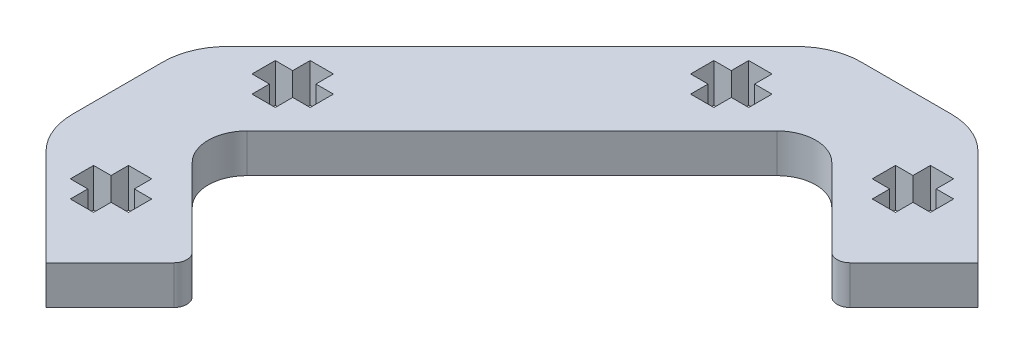
from build123d import *

# Parameters (mm, degrees)
BOSS_EXTRUDE1_DEPTH = 3
CUT_EXTRUDE1_DEPTH  = 4


with BuildPart() as part:
    # Sketch1 → Boss-Extrude1 (new body)
    with BuildSketch(Plane(origin=(0, 0, 0), x_dir=(1, 0, 0), z_dir=(0, 1, 0))):
        with BuildLine():
            Line((-6.037453791, -13.924683413), (-12.047861431, -7.914275773))
            ThreePointArc((-12.047861431, -7.914275773), (-12.926541087, -5.792955429), (-12.047861431, -3.671635086))
            Line((-12.047861431, -3.671635086), (8.458235223, 16.834461569))
            ThreePointArc((8.458235223, 16.834461569), (10.579555567, 17.713141225), (12.700875911, 16.834461569))
            Line((12.700875911, 16.834461569), (18.711283551, 10.824053929))
            ThreePointArc((18.711283551, 10.824053929), (19.418390332, 10.53116071), (20.125497113, 10.824053929))
            Line((20.125497113, 10.824053929), (25.075244581, 15.773801397))
            Line((25.075244581, 15.773801397), (17.606467502, 23.242578477))
            ThreePointArc((17.606467502, 23.242578477), (15.984350757, 24.326442233), (14.070933596, 24.707044571))
            Line((14.070933596, 24.707044571), (7.088177538, 24.707044571))
            ThreePointArc((7.088177538, 24.707044571), (5.174760376, 24.326442233), (3.552643632, 23.242578477))
            Line((3.552643632, 23.242578477), (-18.455978339, 1.233956505))
            ThreePointArc((-18.455978339, 1.233956505), (-19.539842096, -0.388160239), (-19.920444433, -2.301577401))
            Line((-19.920444433, -2.301577401), (-19.920444433, -9.284333458))
            ThreePointArc((-19.920444433, -9.284333458), (-19.539842096, -11.19775062), (-18.455978339, -12.819867364))
            Line((-18.455978339, -12.819867364), (-10.987201259, -20.288644444))
            Line((-10.987201259, -20.288644444), (-6.037453791, -15.338896975))
            ThreePointArc((-6.037453791, -15.338896975), (-5.744560572, -14.631790194), (-6.037453791, -13.924683413))
        make_face()
    extrude(amount=BOSS_EXTRUDE1_DEPTH)

    # Sketch2 → Cut-Extrude1 (cut, through all)
    with BuildSketch(Plane(origin=(0, 3, 0), x_dir=(1, 0, 0), z_dir=(0, 1, 0))):
        Polygon((-15.670444433, 2.136481822), (-15.670444433, 0.336481822), (-14.320444433, 0.336481822), (-14.320444433, -1.013518178), (-12.520444433, -1.013518178), (-12.520444433, 0.336481822), (-11.170444433, 0.336481822), (-11.170444433, 2.136481822), (-12.520444433, 2.136481822), (-12.520444433, 3.486481822), (-14.320444433, 3.486481822), (-14.320444433, 2.136481822), align=None)
        Polygon((-12.520444433, -10.572392681), (-14.320444433, -10.572392681), (-14.320444433, -11.922392681), (-15.670444433, -11.922392681), (-15.670444433, -13.722392681), (-14.320444433, -13.722392681), (-14.320444433, -15.072392681), (-12.520444433, -15.072392681), (-12.520444433, -13.722392681), (-11.170444433, -13.722392681), (-11.170444433, -11.922392681), (-12.520444433, -11.922392681), align=None)
        Polygon((18.508992818, 17.307044571), (19.858992818, 17.307044571), (19.858992818, 19.107044571), (18.508992818, 19.107044571), (18.508992818, 20.457044571), (16.708992818, 20.457044571), (16.708992818, 19.107044571), (15.358992818, 19.107044571), (15.358992818, 17.307044571), (16.708992818, 17.307044571), (16.708992818, 15.957044571), (18.508992818, 15.957044571), align=None)
        Polygon((36.829555567, -13.722392681), (36.829555567, -11.922392681), (35.479555567, -11.922392681), (35.479555567, -10.572392681), (33.679555567, -10.572392681), (33.679555567, -11.922392681), (32.329555567, -11.922392681), (32.329555567, -13.722392681), (33.679555567, -13.722392681), (33.679555567, -15.072392681), (35.479555567, -15.072392681), (35.479555567, -13.722392681), align=None)
        Polygon((5.800118315, 19.107044571), (4.450118315, 19.107044571), (4.450118315, 20.457044571), (2.650118315, 20.457044571), (2.650118315, 19.107044571), (1.300118315, 19.107044571), (1.300118315, 17.307044571), (2.650118315, 17.307044571), (2.650118315, 15.957044571), (4.450118315, 15.957044571), (4.450118315, 17.307044571), (5.800118315, 17.307044571), align=None)
        Polygon((36.829555567, 2.136481822), (35.479555567, 2.136481822), (35.479555567, 3.486481822), (33.679555567, 3.486481822), (33.679555567, 2.136481822), (32.329555567, 2.136481822), (32.329555567, 0.336481822), (33.679555567, 0.336481822), (33.679555567, -1.013518178), (35.479555567, -1.013518178), (35.479555567, 0.336481822), (36.829555567, 0.336481822), align=None)
        Polygon((4.450118315, -32.042955429), (4.450118315, -30.692955429), (5.800118315, -30.692955429), (5.800118315, -28.892955429), (4.450118315, -28.892955429), (4.450118315, -27.542955429), (2.650118315, -27.542955429), (2.650118315, -28.892955429), (1.300118315, -28.892955429), (1.300118315, -30.692955429), (2.650118315, -30.692955429), (2.650118315, -32.042955429), align=None)
        Polygon((18.508992818, -32.042955429), (18.508992818, -30.692955429), (19.858992818, -30.692955429), (19.858992818, -28.892955429), (18.508992818, -28.892955429), (18.508992818, -27.542955429), (16.708992818, -27.542955429), (16.708992818, -28.892955429), (15.358992818, -28.892955429), (15.358992818, -30.692955429), (16.708992818, -30.692955429), (16.708992818, -32.042955429), align=None)
    extrude(amount=-CUT_EXTRUDE1_DEPTH, mode=Mode.SUBTRACT)


solid = part.part
